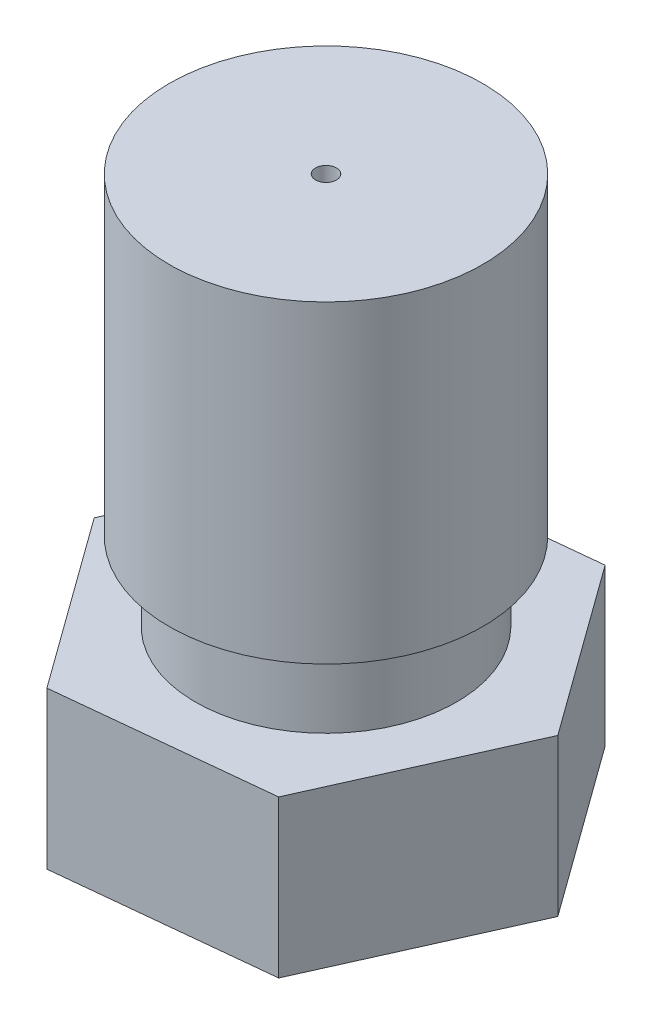
from build123d import *

# Parameters (mm, degrees)
BOSS_EXTRUDE1_DEPTH = 3
SKETCH4_R           = 0.2
CUT_EXTRUDE1_DEPTH  = 13.5


with BuildPart() as part:
    # Sketch2 → Revolve1 (revolve)
    with BuildSketch(Plane.XY):
        Polygon((3, 12.5), (0, 12.5), (0, 0), (0.5, 0), (1.900415076, 2), (3.5, 2), (3.5, 5), (2.5, 5), (2.5, 6.5), (3, 6.5), align=None)
    revolve(axis=Axis((0, 12.5, 0), (0, -1, 0)))

    # Sketch3 → Boss-Extrude1 (add)
    with BuildSketch(Plane.XZ.offset(-2)):
        Polygon((-4.020157505, 0.41432713), (-2.368896572, -3.274394961), (1.651260932, -3.688722091), (4.020157505, -0.41432713), (2.368896572, 3.274394961), (-1.651260932, 3.688722091), align=None)
    extrude(amount=-BOSS_EXTRUDE1_DEPTH)

    # Sketch4 → Cut-Extrude1 (cut, through all)
    with BuildSketch(Plane.XZ):
        Circle(SKETCH4_R)
    extrude(amount=-CUT_EXTRUDE1_DEPTH, mode=Mode.SUBTRACT)


solid = part.part
